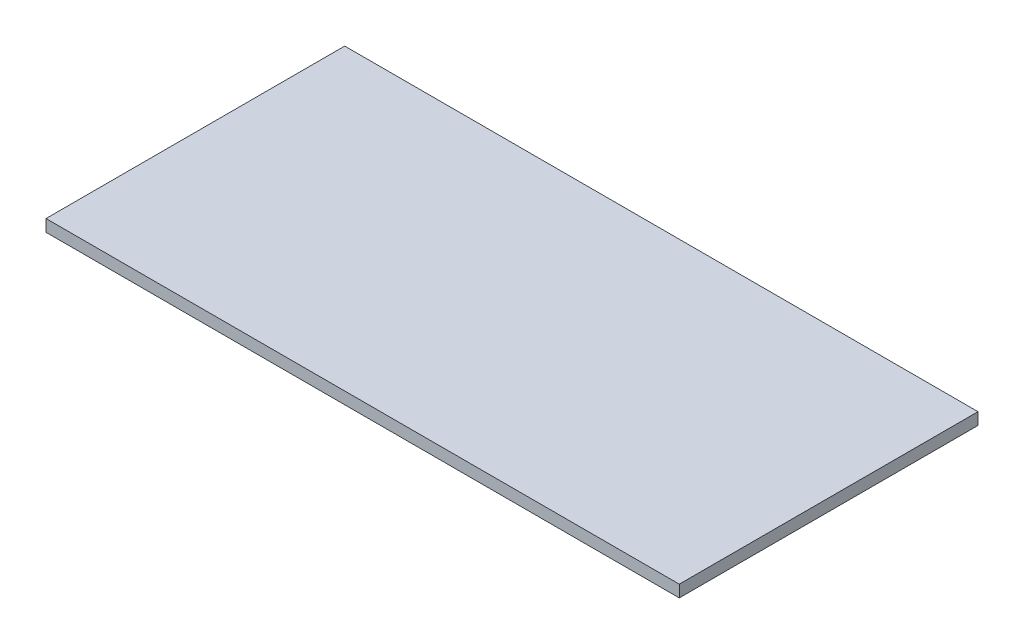
from build123d import *

# Parameters (mm, degrees)
ESQUISSE1_W        = 53
ESQUISSE1_H        = 25
BOSS_EXTRU_1_DEPTH = 1


with BuildPart() as part:
    # Esquisse1 → Boss.-Extru.1 (new body)
    with BuildSketch(Plane(origin=(0, 0, 0), x_dir=(1, 0, 0), z_dir=(0, 1, 0))):
        with Locations((0, -12.5)):
            Rectangle(ESQUISSE1_W, ESQUISSE1_H)
    extrude(amount=BOSS_EXTRU_1_DEPTH)


solid = part.part
